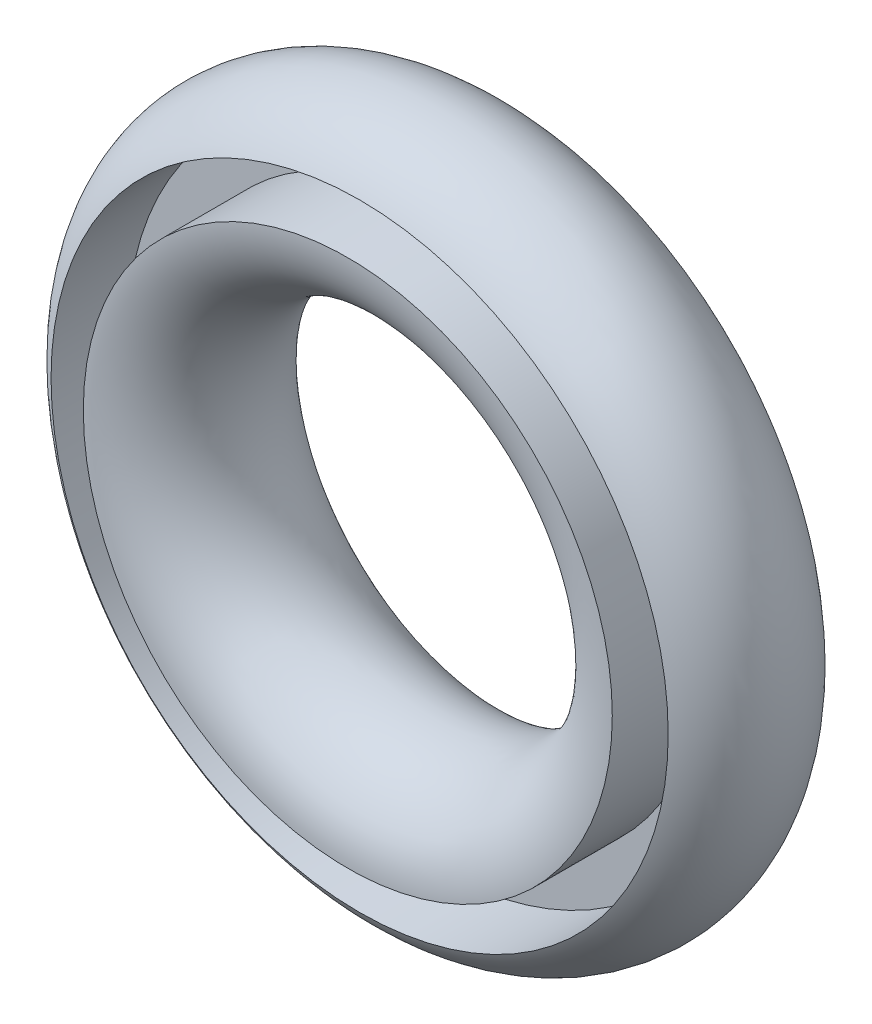
from build123d import *


with BuildPart() as part:
    # 草图2 → 旋转1 (revolve)
    with BuildSketch(Plane(origin=(0, 0, 0), x_dir=(0, 0, -1), z_dir=(1, 0, 0))):
        with BuildLine():
            Line((-5, -15), (0, -15))
            Line((0, -15), (0, -17.5))
            Line((0, -17.5), (-4.330127019, -17.5))
            ThreePointArc((-4.330127019, -17.5), (1.294095226, -19.829629131), (5, -15))
            ThreePointArc((5, -15), (0, -10), (-5, -15))
        make_face()
    revolve(axis=Axis((0, 0, -9.923213432), (0, 0, 1)))


solid = part.part
